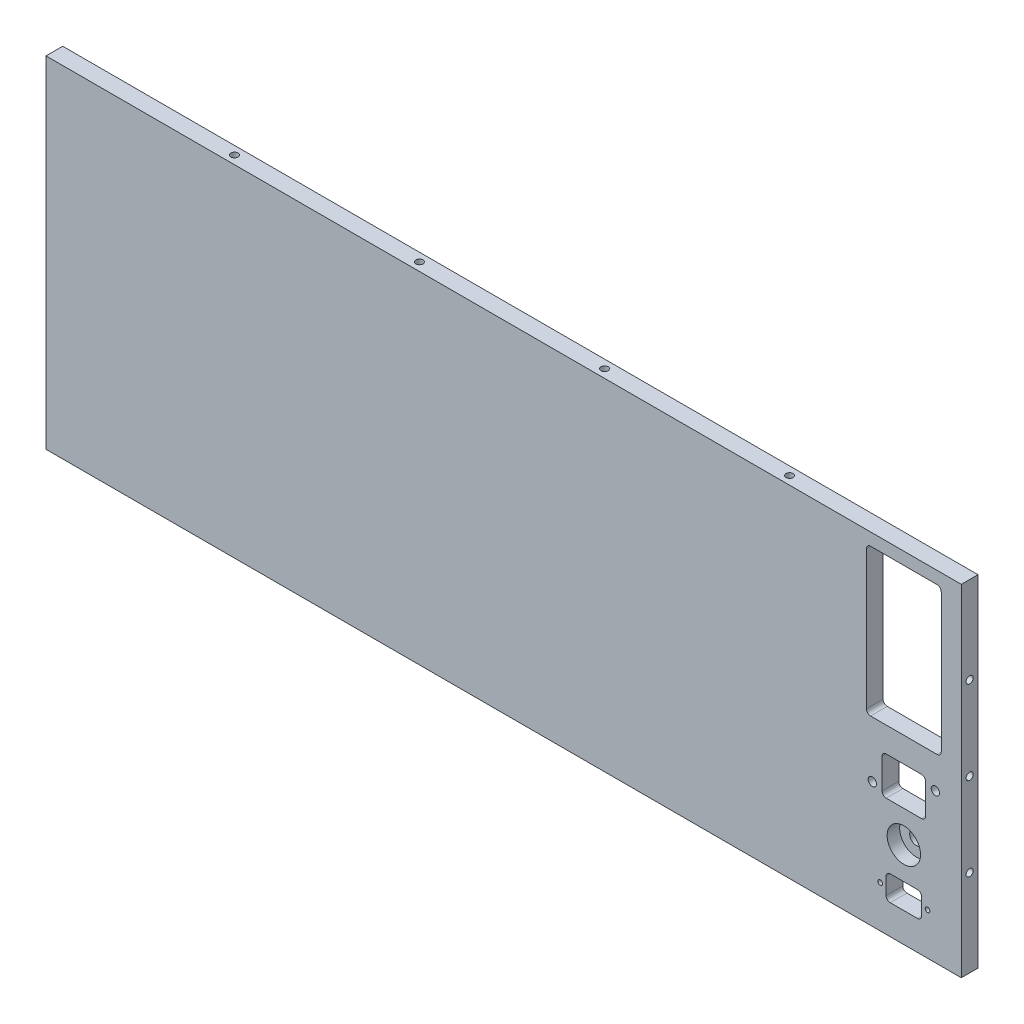
from build123d import *

# Parameters (mm, degrees)
SKETCH1_W                     = 347.98
SKETCH1_H                     = 129.54
BOSS_EXTRUDE1_DEPTH           = 6.35
TAP_DRILL_FOR_6_32_TAP4_D     = 2.7051
TAP_DRILL_FOR_6_32_TAP4_DEPTH = 17.78
TAP_DRILL_FOR_6_32_TAP4_TIP   = 0.81269403
TAP_DRILL_FOR_6_32_TAP1_D     = 2.7051
TAP_DRILL_FOR_6_32_TAP1_DEPTH = 17.78
TAP_DRILL_FOR_6_32_TAP1_TIP   = 0.81269403
TAP_DRILL_FOR_6_32_TAP2_D     = 2.7051
TAP_DRILL_FOR_6_32_TAP2_DEPTH = 17.78
TAP_DRILL_FOR_6_32_TAP2_TIP   = 0.81269403
SKETCH10_R                    = 0.889
SKETCH10_R_2                  = 1.5875
SKETCH10_R_3                  = 2.55
CUT_EXTRUDE1_DEPTH            = 7.35
SKETCH15_R                    = 6.35
CUT_EXTRUDE2_DEPTH            = 4.7625
TAP_DRILL_FOR_6_32_TAP5_D     = 2.7051
TAP_DRILL_FOR_6_32_TAP5_DEPTH = 17.78
TAP_DRILL_FOR_6_32_TAP5_TIP   = 0.81269403


with BuildPart() as part:
    # Sketch1 → Boss-Extrude1 (new body)
    with BuildSketch(Plane.XY):
        with Locations((173.99, 64.77)):
            Rectangle(SKETCH1_W, SKETCH1_H)
    extrude(amount=BOSS_EXTRUDE1_DEPTH)

    # Tap Drill for #6-32 Tap4
    with Locations(Plane(origin=(0, 13.303154199, -243.112488364), x_dir=(0, 0, 1), z_dir=(-1, 0, 0))):
        with Locations((-105.502511636, 81.946845801), (-105.502511636, 56.546845801), (-105.502511636, 31.146845801), (246.287488364, 83.216845801), (246.287488364, 51.466845801), (246.287488364, 19.716845801)):
            Hole(TAP_DRILL_FOR_6_32_TAP4_D / 2, depth=TAP_DRILL_FOR_6_32_TAP4_DEPTH)
            with Locations((0, 0, -(TAP_DRILL_FOR_6_32_TAP4_DEPTH + TAP_DRILL_FOR_6_32_TAP4_TIP / 2))):  # 118° drill point
                Cone(0, TAP_DRILL_FOR_6_32_TAP4_D / 2, TAP_DRILL_FOR_6_32_TAP4_TIP, mode=Mode.SUBTRACT)

    # Tap Drill for #6-32 Tap1
    with Locations(Plane(origin=(-62.924888364, 129.54, 269.187551164), x_dir=(0, 0, -1), z_dir=(0, 1, 0))):
        with Locations((266.012551164, -131.377888364), (266.012551164, -201.735888364), (266.012551164, -272.093888364), (266.012551164, -342.451888364)):
            Hole(TAP_DRILL_FOR_6_32_TAP1_D / 2, depth=TAP_DRILL_FOR_6_32_TAP1_DEPTH)
            with Locations((0, 0, -(TAP_DRILL_FOR_6_32_TAP1_DEPTH + TAP_DRILL_FOR_6_32_TAP1_TIP / 2))):  # 118° drill point
                Cone(0, TAP_DRILL_FOR_6_32_TAP1_D / 2, TAP_DRILL_FOR_6_32_TAP1_TIP, mode=Mode.SUBTRACT)

    # Tap Drill for #6-32 Tap2
    with Locations(Plane(origin=(-62.924888364, 0, 269.187551164), x_dir=(0, 0, 1), z_dir=(0, -1, 0))):
        with Locations((-266.012551164, -342.451888364), (-266.012551164, -272.093888364), (-266.012551164, -201.735888364), (-266.012551164, -131.377888364)):
            Hole(TAP_DRILL_FOR_6_32_TAP2_D / 2, depth=TAP_DRILL_FOR_6_32_TAP2_DEPTH)
            with Locations((0, 0, -(TAP_DRILL_FOR_6_32_TAP2_DEPTH + TAP_DRILL_FOR_6_32_TAP2_TIP / 2))):  # 118° drill point
                Cone(0, TAP_DRILL_FOR_6_32_TAP2_D / 2, TAP_DRILL_FOR_6_32_TAP2_TIP, mode=Mode.SUBTRACT)

    # Sketch10 → Cut-Extrude1 (cut, through all)
    with BuildSketch(Plane.XY.offset(6.35)):
        with Locations((335.136, 15.9564)):
            Circle(SKETCH10_R)
        with Locations((317.136, 15.9564)):
            Circle(SKETCH10_R)
        with Locations((338.1248, 56.6293)):
            Circle(SKETCH10_R_2)
        with Locations((314.1472, 47.6377)):
            Circle(SKETCH10_R_2)
        with Locations((326.136, 32.7814)):
            Circle(SKETCH10_R_3)
        with BuildLine():
            Line((313.4995, 124.841), (338.7725, 124.841))
            ThreePointArc((338.7725, 124.841), (339.895032015, 124.376032015), (340.36, 123.2535))
            Line((340.36, 123.2535), (340.36, 70.5231))
            ThreePointArc((340.36, 70.5231), (339.895032015, 69.400567985), (338.7725, 68.9356))
            Line((338.7725, 68.9356), (313.4995, 68.9356))
            ThreePointArc((313.4995, 68.9356), (312.376967985, 69.400567985), (311.912, 70.5231))
            Line((311.912, 70.5231), (311.912, 123.2535))
            ThreePointArc((311.912, 123.2535), (312.376967985, 124.376032015), (313.4995, 124.841))
        make_face()
        with BuildLine():
            Line((331.2985, 20.7064), (320.9735, 20.7064))
            ThreePointArc((320.9735, 20.7064), (319.850967985, 20.241432015), (319.386, 19.1189))
            Line((319.386, 19.1189), (319.386, 12.7939))
            ThreePointArc((319.386, 12.7939), (319.850967985, 11.671367985), (320.9735, 11.2064))
            Line((320.9735, 11.2064), (331.2985, 11.2064))
            ThreePointArc((331.2985, 11.2064), (332.421032015, 11.671367985), (332.886, 12.7939))
            Line((332.886, 12.7939), (332.886, 19.1189))
            ThreePointArc((332.886, 19.1189), (332.421032015, 20.241432015), (331.2985, 20.7064))
        make_face()
        with BuildLine():
            Line((332.8289, 59.4106), (319.4431, 59.4106))
            ThreePointArc((319.4431, 59.4106), (318.320567985, 58.945632015), (317.8556, 57.8231))
            Line((317.8556, 57.8231), (317.8556, 46.4439))
            ThreePointArc((317.8556, 46.4439), (318.320567985, 45.321367985), (319.4431, 44.8564))
            Line((319.4431, 44.8564), (332.8289, 44.8564))
            ThreePointArc((332.8289, 44.8564), (333.951432015, 45.321367985), (334.4164, 46.4439))
            Line((334.4164, 46.4439), (334.4164, 57.8231))
            ThreePointArc((334.4164, 57.8231), (333.951432015, 58.945632015), (332.8289, 59.4106))
        make_face()
    extrude(amount=-CUT_EXTRUDE1_DEPTH, mode=Mode.SUBTRACT)

    # Sketch15 → Cut-Extrude2 (cut)
    with BuildSketch(Plane.XY.offset(6.35)):
        with Locations((326.136, 32.7814)):
            Circle(SKETCH15_R)
    extrude(amount=-CUT_EXTRUDE2_DEPTH, mode=Mode.SUBTRACT)

    # Tap Drill for #6-32 Tap5
    with Locations(Plane(origin=(347.98, 0, 0), x_dir=(0, 0, -1), z_dir=(1, 0, 0))):
        with Locations((-3.175, 64.77), (-3.175, 96.52), (-3.175, 33.02)):
            Hole(TAP_DRILL_FOR_6_32_TAP5_D / 2, depth=TAP_DRILL_FOR_6_32_TAP5_DEPTH)
            with Locations((0, 0, -(TAP_DRILL_FOR_6_32_TAP5_DEPTH + TAP_DRILL_FOR_6_32_TAP5_TIP / 2))):  # 118° drill point
                Cone(0, TAP_DRILL_FOR_6_32_TAP5_D / 2, TAP_DRILL_FOR_6_32_TAP5_TIP, mode=Mode.SUBTRACT)


solid = part.part
